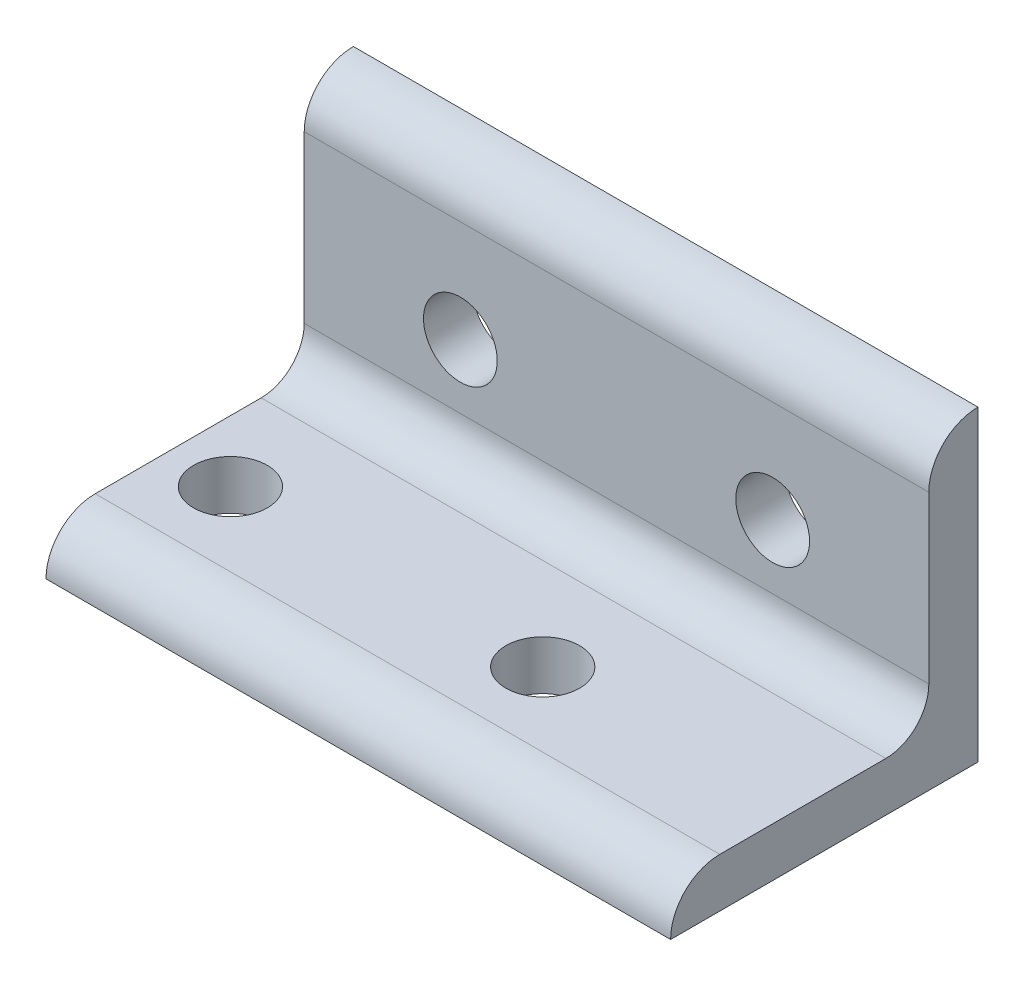
from build123d import *

# Parameters (mm, degrees)
STRUCTURAL_MEMBER1_DEPTH = 50.8
SKETCH13_R               = 3
CUT_EXTRUDE1_DEPTH       = 45.745454998
SKETCH14_R               = 3
CUT_EXTRUDE2_DEPTH       = 45.745454998


with BuildPart() as part:
    # Sketch12 → Structural Member1 (new body)
    with BuildSketch(Plane.YZ.offset(-30.596662285)):
        with BuildLine():
            Line((0, 0), (0, 25))
            ThreePointArc((0, 25), (2.828427125, 23.828427125), (4, 21))
            Line((4, 21), (4, 7.5))
            ThreePointArc((4, 7.5), (5.025126266, 5.025126266), (7.5, 4))
            Line((7.5, 4), (21, 4))
            ThreePointArc((21, 4), (23.828427125, 2.828427125), (25, 0))
            Line((25, 0), (0, 0))
        make_face()
    extrude(amount=STRUCTURAL_MEMBER1_DEPTH)

    # Sketch13 → Cut-Extrude1 (cut, through all)
    with BuildSketch(Plane.XY.offset(4)):
        with Locations((-17.896662285, 12.7)):
            Circle(SKETCH13_R)
        with Locations((7.503337715, 12.7)):
            Circle(SKETCH13_R)
    extrude(amount=-CUT_EXTRUDE1_DEPTH, mode=Mode.SUBTRACT)

    # Sketch14 → Cut-Extrude2 (cut, through all)
    with BuildSketch(Plane(origin=(0, 4, 0), x_dir=(-1, 0, 0), z_dir=(0, 1, 0))):
        with Locations(Location((25.596662285, 15, 0), (0, 0, 90))):
            Circle(SKETCH14_R)
        with Locations(Location((0.196662285, 15, 0), (0, 0, 90))):
            Circle(SKETCH14_R)
    extrude(amount=-CUT_EXTRUDE2_DEPTH, mode=Mode.SUBTRACT)


solid = part.part
